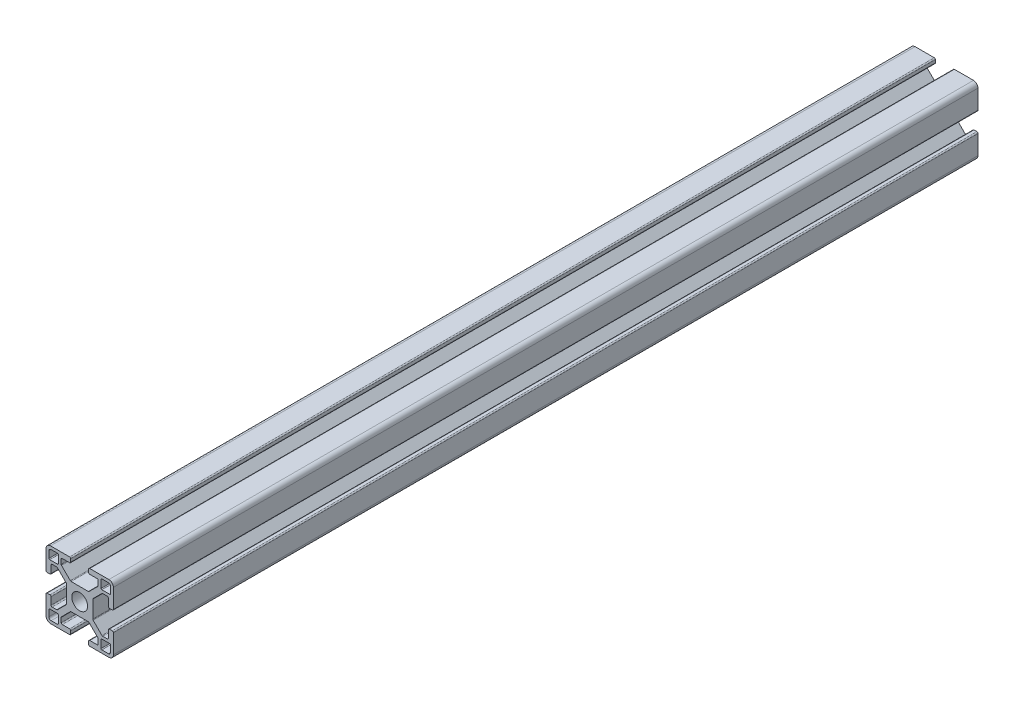
from build123d import *

# Parameters (mm, degrees)
SKETCH1_R           = 3.52998588
BOSS_EXTRUDE1_DEPTH = 192.5


with BuildPart() as part:
    # Sketch1 → Boss-Extrude1 (new body, symmetric)
    with BuildSketch(Plane.XY):
        with BuildLine():
            Line((14.49994, -4), (13.24247465, -4))
            ThreePointArc((13.24247465, -4), (12.88892126, -4.146446609), (12.74247465, -4.5))
            Line((12.74247465, -4.5), (12.74247465, -7.732519321))
            ThreePointArc((12.74247465, -7.732519321), (12.602449697, -8.097296796), (12.242781236, -8.249967))
            Line((12.242781236, -8.249967), (10.260188032, -8.249967))
            ThreePointArc((10.260188032, -8.249967), (10.068847082, -8.211906919), (9.906636056, -8.103520976))
            Line((9.906636056, -8.103520976), (5.981117769, -4.178002689))
            ThreePointArc((5.981117769, -4.178002689), (5.872731827, -4.015791664), (5.834671745, -3.824450713))
            Line((5.834671745, -3.824450713), (5.834671745, -1.01249595))
            Line((5.834671745, -1.01249595), (5.834671745, 0.88749645))
            Line((5.834671745, 0.88749645), (5.834671745, 3.824450713))
            ThreePointArc((5.834671745, 3.824450713), (5.872731827, 4.015791664), (5.981117769, 4.178002689))
            Line((5.981117769, 4.178002689), (9.906636056, 8.103520976))
            ThreePointArc((9.906636056, 8.103520976), (10.068847082, 8.211906919), (10.260188032, 8.249967))
            Line((10.260188032, 8.249967), (12.242781236, 8.249967))
            ThreePointArc((12.242781236, 8.249967), (12.602449697, 8.097296796), (12.74247465, 7.732519321))
            Line((12.74247465, 7.732519321), (12.74247465, 4.5))
            ThreePointArc((12.74247465, 4.5), (12.88892126, 4.146446609), (13.24247465, 4))
            Line((13.24247465, 4), (14.49994, 4))
            ThreePointArc((14.49994, 4), (14.853493391, 4.146446609), (14.99994, 4.5))
            Line((14.99994, 4.5), (14.99994, 12.999948))
            ThreePointArc((14.99994, 12.999948), (14.414155906, 14.414155906), (12.999948, 14.99994))
            Line((12.999948, 14.99994), (4.5, 14.99994))
            ThreePointArc((4.5, 14.99994), (4.146446609, 14.853493391), (4, 14.49994))
            Line((4, 14.49994), (4, 13.24247465))
            ThreePointArc((4, 13.24247465), (4.146446609, 12.88892126), (4.5, 12.74247465))
            Line((4.5, 12.74247465), (7.732519321, 12.74247465))
            ThreePointArc((7.732519321, 12.74247465), (8.097296796, 12.602449697), (8.249967, 12.242781236))
            Line((8.249967, 12.242781236), (8.249967, 10.260188032))
            ThreePointArc((8.249967, 10.260188032), (8.211906919, 10.068847082), (8.103520976, 9.906636056))
            Line((8.103520976, 9.906636056), (4.178002689, 5.981117769))
            ThreePointArc((4.178002689, 5.981117769), (4.015791664, 5.872731827), (3.824450713, 5.834671745))
            Line((3.824450713, 5.834671745), (0.9499962, 5.834671745))
            Line((0.9499962, 5.834671745), (-0.9499962, 5.834671745))
            Line((-0.9499962, 5.834671745), (-3.824450713, 5.834671745))
            ThreePointArc((-3.824450713, 5.834671745), (-4.015791664, 5.872731827), (-4.178002689, 5.981117769))
            Line((-4.178002689, 5.981117769), (-8.103520976, 9.906636056))
            ThreePointArc((-8.103520976, 9.906636056), (-8.211906919, 10.068847082), (-8.249967, 10.260188032))
            Line((-8.249967, 10.260188032), (-8.249967, 12.242781236))
            ThreePointArc((-8.249967, 12.242781236), (-8.097296796, 12.602449697), (-7.732519321, 12.74247465))
            Line((-7.732519321, 12.74247465), (-4.5, 12.74247465))
            ThreePointArc((-4.5, 12.74247465), (-4.146446609, 12.88892126), (-4, 13.24247465))
            Line((-4, 13.24247465), (-4, 14.49994))
            ThreePointArc((-4, 14.49994), (-4.146446609, 14.853493391), (-4.5, 14.99994))
            Line((-4.5, 14.99994), (-12.999948, 14.99994))
            ThreePointArc((-12.999948, 14.99994), (-14.414155906, 14.414155906), (-14.99994, 12.999948))
            Line((-14.99994, 12.999948), (-14.99994, 4.5))
            ThreePointArc((-14.99994, 4.5), (-14.853493391, 4.146446609), (-14.49994, 4))
            Line((-14.49994, 4), (-13.24247465, 4))
            ThreePointArc((-13.24247465, 4), (-12.88892126, 4.146446609), (-12.74247465, 4.5))
            Line((-12.74247465, 4.5), (-12.74247465, 7.732519321))
            ThreePointArc((-12.74247465, 7.732519321), (-12.602449697, 8.097296796), (-12.242781236, 8.249967))
            Line((-12.242781236, 8.249967), (-10.260188032, 8.249967))
            ThreePointArc((-10.260188032, 8.249967), (-10.068847082, 8.211906919), (-9.906636056, 8.103520976))
            Line((-9.906636056, 8.103520976), (-5.981117769, 4.178002689))
            ThreePointArc((-5.981117769, 4.178002689), (-5.872731827, 4.015791664), (-5.834671745, 3.824450713))
            Line((-5.834671745, 3.824450713), (-5.834671745, 0.88749645))
            Line((-5.834671745, 0.88749645), (-5.834671745, -1.01249595))
            Line((-5.834671745, -1.01249595), (-5.834671745, -3.824450713))
            ThreePointArc((-5.834671745, -3.824450713), (-5.872731827, -4.015791664), (-5.981117769, -4.178002689))
            Line((-5.981117769, -4.178002689), (-9.906636056, -8.103520976))
            ThreePointArc((-9.906636056, -8.103520976), (-10.068847082, -8.211906919), (-10.260188032, -8.249967))
            Line((-10.260188032, -8.249967), (-12.242781236, -8.249967))
            ThreePointArc((-12.242781236, -8.249967), (-12.602449697, -8.097296796), (-12.74247465, -7.732519321))
            Line((-12.74247465, -7.732519321), (-12.74247465, -4.5))
            ThreePointArc((-12.74247465, -4.5), (-12.88892126, -4.146446609), (-13.24247465, -4))
            Line((-13.24247465, -4), (-14.49994, -4))
            ThreePointArc((-14.49994, -4), (-14.853493391, -4.146446609), (-14.99994, -4.5))
            Line((-14.99994, -4.5), (-14.99994, -12.999948))
            ThreePointArc((-14.99994, -12.999948), (-14.414155906, -14.414155906), (-12.999948, -14.99994))
            Line((-12.999948, -14.99994), (-4.5, -14.99994))
            ThreePointArc((-4.5, -14.99994), (-4.146446609, -14.853493391), (-4, -14.49994))
            Line((-4, -14.49994), (-4, -13.24247465))
            ThreePointArc((-4, -13.24247465), (-4.146446609, -12.88892126), (-4.5, -12.74247465))
            Line((-4.5, -12.74247465), (-7.732519321, -12.74247465))
            ThreePointArc((-7.732519321, -12.74247465), (-8.097296796, -12.602449697), (-8.249967, -12.242781236))
            Line((-8.249967, -12.242781236), (-8.249967, -10.260188032))
            ThreePointArc((-8.249967, -10.260188032), (-8.211906919, -10.068847082), (-8.103520976, -9.906636056))
            Line((-8.103520976, -9.906636056), (-4.178002689, -5.981117769))
            ThreePointArc((-4.178002689, -5.981117769), (-4.015791664, -5.872731827), (-3.824450713, -5.834671745))
            Line((-3.824450713, -5.834671745), (-0.9499962, -5.834671745))
            Line((-0.9499962, -5.834671745), (0.9499962, -5.834671745))
            Line((0.9499962, -5.834671745), (3.824450713, -5.834671745))
            ThreePointArc((3.824450713, -5.834671745), (4.015791664, -5.872731827), (4.178002689, -5.981117769))
            Line((4.178002689, -5.981117769), (8.103520976, -9.906636056))
            ThreePointArc((8.103520976, -9.906636056), (8.211906919, -10.068847082), (8.249967, -10.260188032))
            Line((8.249967, -10.260188032), (8.249967, -12.242781236))
            ThreePointArc((8.249967, -12.242781236), (8.097296796, -12.602449697), (7.732519321, -12.74247465))
            Line((7.732519321, -12.74247465), (4.5, -12.74247465))
            ThreePointArc((4.5, -12.74247465), (4.146446609, -12.88892126), (4, -13.24247465))
            Line((4, -13.24247465), (4, -14.49994))
            ThreePointArc((4, -14.49994), (4.146446609, -14.853493391), (4.5, -14.99994))
            Line((4.5, -14.99994), (12.999948, -14.99994))
            ThreePointArc((12.999948, -14.99994), (14.414155906, -14.414155906), (14.99994, -12.999948))
            Line((14.99994, -12.999948), (14.99994, -4.5))
            ThreePointArc((14.99994, -4.5), (14.853493391, -4.146446609), (14.49994, -4))
        make_face()
        Circle(SKETCH1_R, mode=Mode.SUBTRACT)
        with BuildLine():
            Line((-12.6999492, -13.6999452), (-9.880960476, -13.6999452))
            ThreePointArc((-9.880960476, -13.6999452), (-9.61155387, -13.58835333), (-9.499962, -13.318946724))
            Line((-9.499962, -13.318946724), (-9.499962, -9.87996048))
            ThreePointArc((-9.499962, -9.87996048), (-9.611260978, -9.611260978), (-9.87996048, -9.499962))
            Line((-9.87996048, -9.499962), (-13.318946724, -9.499962))
            ThreePointArc((-13.318946724, -9.499962), (-13.58835333, -9.61155387), (-13.6999452, -9.880960476))
            Line((-13.6999452, -9.880960476), (-13.6999452, -12.6999492))
            ThreePointArc((-13.6999452, -12.6999492), (-13.407053153, -13.407053153), (-12.6999492, -13.6999452))
        make_face(mode=Mode.SUBTRACT)
        with BuildLine():
            Line((13.6999452, -12.6999492), (13.6999452, -9.880960476))
            ThreePointArc((13.6999452, -9.880960476), (13.58835333, -9.61155387), (13.318946724, -9.499962))
            Line((13.318946724, -9.499962), (9.87996048, -9.499962))
            ThreePointArc((9.87996048, -9.499962), (9.611260978, -9.611260978), (9.499962, -9.87996048))
            Line((9.499962, -9.87996048), (9.499962, -13.318946724))
            ThreePointArc((9.499962, -13.318946724), (9.61155387, -13.58835333), (9.880960476, -13.6999452))
            Line((9.880960476, -13.6999452), (12.6999492, -13.6999452))
            ThreePointArc((12.6999492, -13.6999452), (13.407053153, -13.407053153), (13.6999452, -12.6999492))
        make_face(mode=Mode.SUBTRACT)
        with BuildLine():
            Line((9.87996048, 9.499962), (13.318946724, 9.499962))
            ThreePointArc((13.318946724, 9.499962), (13.58835333, 9.61155387), (13.6999452, 9.880960476))
            Line((13.6999452, 9.880960476), (13.6999452, 12.6999492))
            ThreePointArc((13.6999452, 12.6999492), (13.407053153, 13.407053153), (12.6999492, 13.6999452))
            Line((12.6999492, 13.6999452), (9.880960476, 13.6999452))
            ThreePointArc((9.880960476, 13.6999452), (9.61155387, 13.58835333), (9.499962, 13.318946724))
            Line((9.499962, 13.318946724), (9.499962, 9.87996048))
            ThreePointArc((9.499962, 9.87996048), (9.611260978, 9.611260978), (9.87996048, 9.499962))
        make_face(mode=Mode.SUBTRACT)
        with BuildLine():
            Line((-13.6999452, 12.6999492), (-13.6999452, 9.880960476))
            ThreePointArc((-13.6999452, 9.880960476), (-13.58835333, 9.61155387), (-13.318946724, 9.499962))
            Line((-13.318946724, 9.499962), (-9.87996048, 9.499962))
            ThreePointArc((-9.87996048, 9.499962), (-9.611260978, 9.611260978), (-9.499962, 9.87996048))
            Line((-9.499962, 9.87996048), (-9.499962, 13.318946724))
            ThreePointArc((-9.499962, 13.318946724), (-9.61155387, 13.58835333), (-9.880960476, 13.6999452))
            Line((-9.880960476, 13.6999452), (-12.6999492, 13.6999452))
            ThreePointArc((-12.6999492, 13.6999452), (-13.407053153, 13.407053153), (-13.6999452, 12.6999492))
        make_face(mode=Mode.SUBTRACT)
    extrude(amount=BOSS_EXTRUDE1_DEPTH, both=True)


solid = part.part
